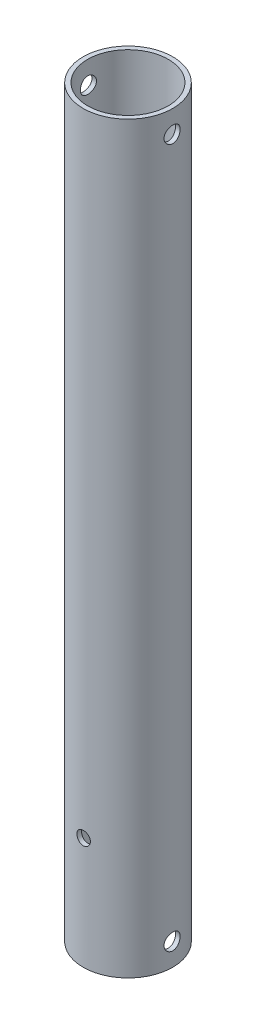
from build123d import *

# Parameters (mm, degrees)
SKETCH1_R            = 10
SKETCH1_R_2          = 9
BOSS_EXTRUDE1_DEPTH  = 166
M3_CLEARANCE_HOLE1_D = 3.6
CUT_EXTRUDE1_REACH   = 168.601
SKETCH7_R            = 1.5
SKETCH8_R            = 1.5
CUT_EXTRUDE2_DEPTH   = 167.601320639


with BuildPart() as part:
    # Sketch1 → Boss-Extrude1 (new body)
    with BuildSketch(Plane(origin=(0, 0, 0), x_dir=(1, 0, 0), z_dir=(0, 1, 0))):
        Circle(SKETCH1_R)
        Circle(SKETCH1_R_2, mode=Mode.SUBTRACT)
    extrude(amount=BOSS_EXTRUDE1_DEPTH)

    # M3 Clearance Hole1 (through all)
    with Locations(Plane(origin=(10, 0, 0), x_dir=(0, 0, -1), z_dir=(1, 0, 0))):
        with Locations((0, 5)):
            m3_clearance_hole1 = Hole(M3_CLEARANCE_HOLE1_D / 2)

    # Mirror1: M3 Clearance Hole1 across plane
    add(m3_clearance_hole1.mirror(Plane.ZX.offset(83)), mode=Mode.SUBTRACT)

    # Sketch7 → Cut-Extrude1 (cut, up to next)
    with BuildSketch(Plane.XY, mode=Mode.PRIVATE) as cut_extrude1_sk1:
        with Locations((0, 25)):
            Circle(SKETCH7_R)
    cut_extrude1_tool1 = extrude(cut_extrude1_sk1.sketch, amount=CUT_EXTRUDE1_REACH, mode=Mode.PRIVATE) & part.part
    add(cut_extrude1_tool1.solids().sort_by_distance((0, 25, 0))[0], mode=Mode.SUBTRACT)

    # Sketch8 → Cut-Extrude2 (cut, through all)
    with BuildSketch(Plane.XY):
        with Locations((0, 141)):
            Circle(SKETCH8_R)
    extrude(amount=-CUT_EXTRUDE2_DEPTH, mode=Mode.SUBTRACT)


solid = part.part
